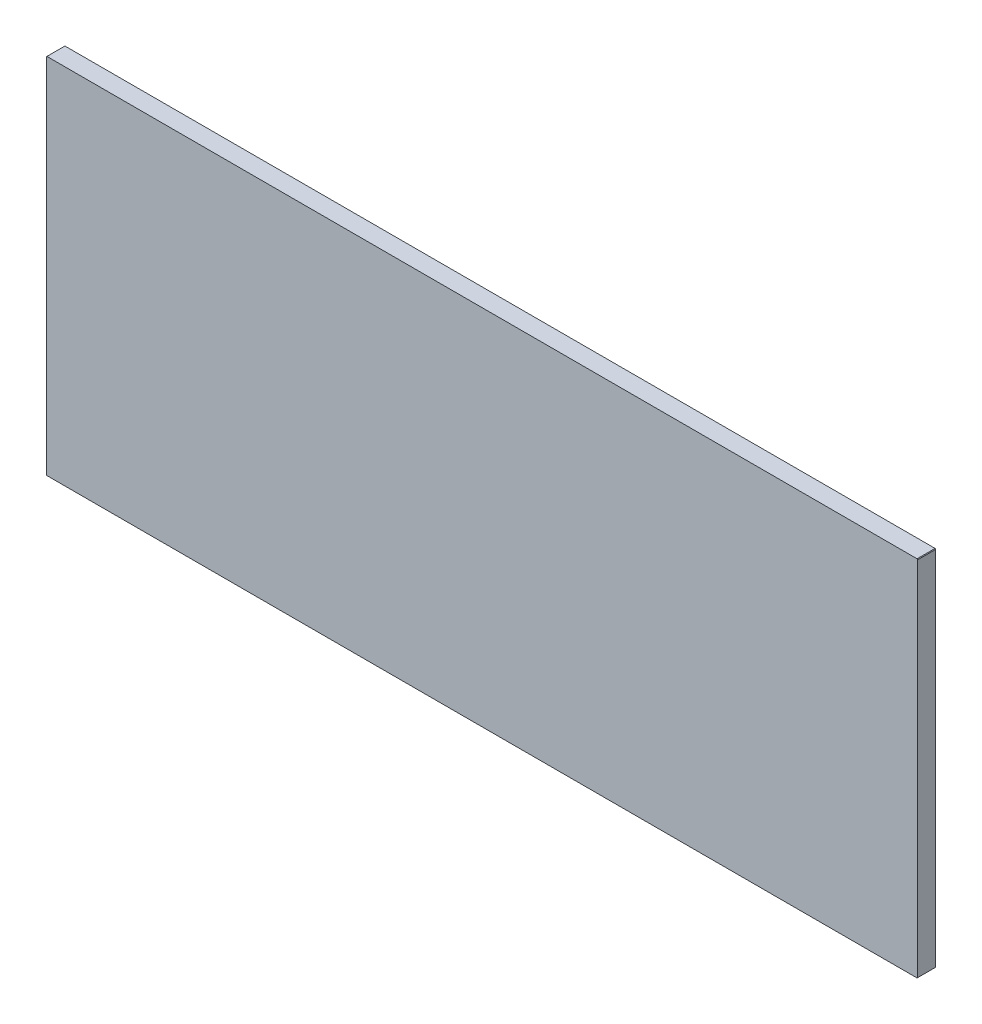
from build123d import *

# Parameters (mm, degrees)
EXTRUDE1_DEPTH = 0.7874


with BuildPart() as part:
    # Sketch1 → Extrude1 (new body)
    with BuildSketch(Plane.XY):
        Polygon((-38.0746, 15.875), (-38.1, 15.8496), (-38.1, 0.0254), (-38.0746, 0), (-0.0254, 0), (0, 0.0254), (0, 15.8496), (-0.0254, 15.875), align=None)
    extrude(amount=EXTRUDE1_DEPTH)


solid = part.part
